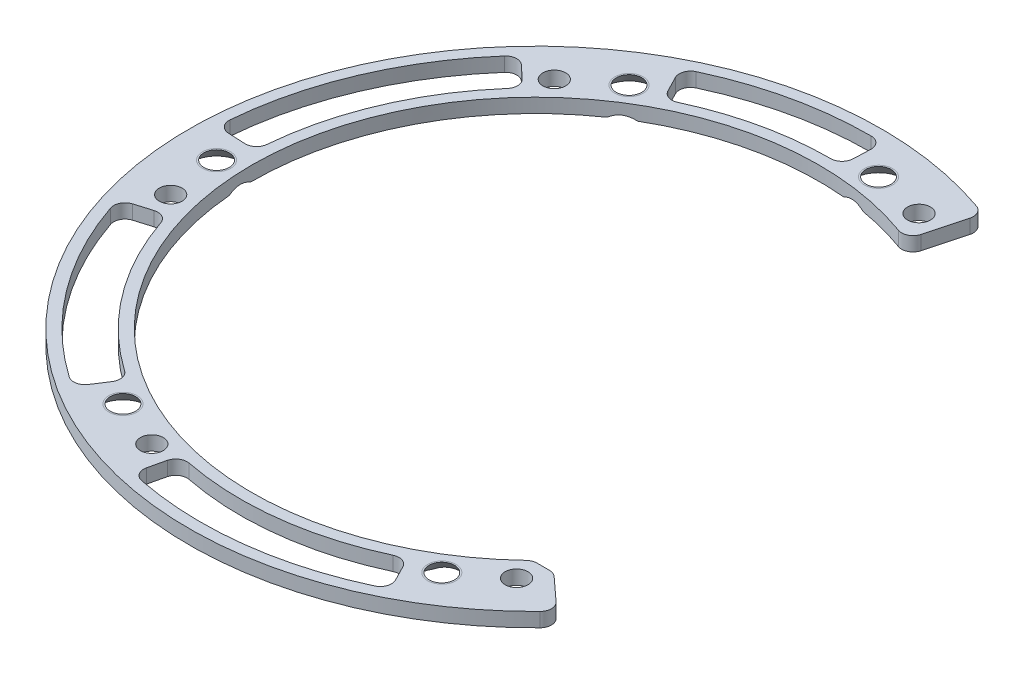
from build123d import *

# Parameters (mm, degrees)
BOSS_EXTRUDE1_DEPTH                          = 3.175
F_10_CLEARANCE_HOLE1_D                       = 5.1054
F_10_CLEARANCE_HOLE1_DEPTH                   = 3.175
CSK_FOR_10_FLAT_HEAD_MACHINE_SCREW1_AT_COUNT = 2
CSK_FOR_10_FLAT_HEAD_MACHINE_SCREW1_AT_PITCH = 46.824609742
CSK_FOR_10_FLAT_HEAD_MACHINE_SCREW1_2_COUNT  = 2
CSK_FOR_10_FLAT_HEAD_MACHINE_SCREW1_2_PITCH  = 104.87608053
CSK_FOR_10_FLAT_HEAD_MACHINE_SCREW1_3_COUNT  = 2
CSK_FOR_10_FLAT_HEAD_MACHINE_SCREW1_3_PITCH  = 134.826090234
CSK_FOR_10_FLAT_HEAD_MACHINE_SCREW1_4_COUNT  = 2
CSK_FOR_10_FLAT_HEAD_MACHINE_SCREW1_4_PITCH  = 128.649557941
FILLET1_R                                    = 2.54
CUT_EXTRUDE1_REACH                           = 5.175


with BuildPart() as part:
    # Sketch6 → Boss-Extrude1 (new body)
    with BuildSketch(Plane(origin=(0, -75.25766, 0), x_dir=(1, 0, 0), z_dir=(0, 1, 0))):
        with BuildLine():
            ThreePointArc((27.776705308, 72.346331375), (-75.433008797, -17.75945396), (57.135602127, -52.355133375))
            Line((57.135602127, -52.355133375), (49.374216067, -45.243133375))
            Line((49.374216067, -45.243133375), (44.556805119, -45.243133375))
            ThreePointArc((44.556805119, -45.243133375), (-62.309050026, -12.240599855), (24.13, 58.736641886))
            Line((24.13, 58.736641886), (27.776705308, 72.346331375))
        make_face()
    extrude(amount=-BOSS_EXTRUDE1_DEPTH)

    # #10 Clearance Hole1
    with Locations(Plane(origin=(0, -75.25766, 0), x_dir=(1, 0, 0), z_dir=(0, 1, 0))):
        with Locations((-46.246176482, 50.468845537), (20.584214093, 65.28478643), (-66.830390575, -14.815940893), (-20.584214093, -65.28478643), (46.246176482, -50.468845537)):
            Hole(F_10_CLEARANCE_HOLE1_D / 2, depth=F_10_CLEARANCE_HOLE1_DEPTH)

    # Sketch10 → CSK for #10 Flat Head Machine Screw1 (revolve, cut)
    with BuildSketch(Plane(origin=(8.934909436, -78.43266, -67.867375096), x_dir=(0, 0, -1), z_dir=(1, 0, 0))):
        Polygon((0, 0), (0, 3.175), (2.5527, 3.175), (2.5527, 3.506322905), (5.6007, 0), align=None)
    csk_for_10_flat_head_machine_screw1 = revolve(axis=Axis((8.934909436, -84.78266, -67.867375096), (0, 1, 0)), mode=Mode.SUBTRACT)

    # CSK for #10 Flat Head Machine Screw1 at: CSK for #10 Flat Head Machine Screw1 ×2
    with Locations(*[Vector(-0.976296007, 0, 0.216439614) * (i * CSK_FOR_10_FLAT_HEAD_MACHINE_SCREW1_AT_PITCH) for i in range(1, CSK_FOR_10_FLAT_HEAD_MACHINE_SCREW1_AT_COUNT)]):
        add(csk_for_10_flat_head_machine_screw1, mode=Mode.SUBTRACT)

    # CSK for _10 Flat Head Machine Screw1 2: CSK for #10 Flat Head Machine Screw1 ×2
    with Locations(*[Vector(-0.737277337, 0, 0.675590208) * (i * CSK_FOR_10_FLAT_HEAD_MACHINE_SCREW1_2_PITCH) for i in range(1, CSK_FOR_10_FLAT_HEAD_MACHINE_SCREW1_2_COUNT)]):
        add(csk_for_10_flat_head_machine_screw1, mode=Mode.SUBTRACT)

    # CSK for _10 Flat Head Machine Screw1 3: CSK for #10 Flat Head Machine Screw1 ×2
    with Locations(*[Vector(-0.3007058, 0, 0.953716951) * (i * CSK_FOR_10_FLAT_HEAD_MACHINE_SCREW1_3_PITCH) for i in range(1, CSK_FOR_10_FLAT_HEAD_MACHINE_SCREW1_3_COUNT)]):
        add(csk_for_10_flat_head_machine_screw1, mode=Mode.SUBTRACT)

    # CSK for _10 Flat Head Machine Screw1 4: CSK for #10 Flat Head Machine Screw1 ×2
    with Locations(*[Vector(0.216439614, 0, 0.976296007) * (i * CSK_FOR_10_FLAT_HEAD_MACHINE_SCREW1_4_PITCH) for i in range(1, CSK_FOR_10_FLAT_HEAD_MACHINE_SCREW1_4_COUNT)]):
        add(csk_for_10_flat_head_machine_screw1, mode=Mode.SUBTRACT)

    # Fillet1
    fillet1_edges = [part.edges().sort_by_distance(p)[0] for p in [
        (24.13, -76.84516, -58.736641886),
        (27.776705308, -76.84516, -72.346331375),
        (57.135602127, -76.84516, 52.355133375),
        (49.374216067, -76.84516, 45.243133375),
        (44.556805119, -76.84516, 45.243133375),
    ]]
    fillet(fillet1_edges, radius=FILLET1_R)

    # Sketch14 → Cut-Extrude1 (cut, up to next)
    with BuildSketch(Plane(origin=(0, -75.25766, 0), x_dir=(1, 0, 0), z_dir=(0, 1, 0)), mode=Mode.PRIVATE) as cut_extrude1_sk1:
        with BuildLine():
            Line((-33.055101826, 64.380888472), (-31.302158707, 60.966709443))
            ThreePointArc((-31.302158707, 60.966709443), (-29.864658567, 59.723557233), (-27.966930931, 59.825850385))
            ThreePointArc((-27.966930931, 59.825850385), (-14.293672104, 64.47458831), (0.063150386, 66.039969806))
            ThreePointArc((0.063150386, 66.039969806), (1.826306674, 66.749275081), (2.603745418, 68.483467419))
            Line((2.603745418, 68.483467419), (2.749557011, 72.318590234))
            ThreePointArc((2.749557011, 72.318590234), (2.043811589, 74.174021303), (0.21880546, 74.955080637))
            ThreePointArc((0.21880546, 74.955080637), (-16.223317839, 73.178657732), (-31.87569098, 67.839902076))
            ThreePointArc((-31.87569098, 67.839902076), (-33.199618308, 66.360741002), (-33.055101826, 64.380888472))
        make_face()
    cut_extrude1_tool1 = extrude(cut_extrude1_sk1.sketch, amount=-CUT_EXTRUDE1_REACH, mode=Mode.PRIVATE) & part.part
    add(cut_extrude1_tool1.solids().sort_by_distance((-15.117133, -75.25766, -68.188982))[0], mode=Mode.SUBTRACT)
    # Sketch14 → Cut-Extrude1 (cut, up to next)
    with BuildSketch(Plane(origin=(0, -75.25766, 0), x_dir=(1, 0, 0), z_dir=(0, 1, 0)), mode=Mode.PRIVATE) as cut_extrude1_sk2:
        with BuildLine():
            Line((-52.717941235, 49.581823576), (-49.92225926, 46.952452868))
            ThreePointArc((-49.92225926, 46.952452868), (-49.125502701, 45.22705058), (-49.749009498, 43.431758587))
            ThreePointArc((-49.749009498, 43.431758587), (-60.775101299, 25.839285248), (-65.794171702, 5.69285254))
            ThreePointArc((-65.794171702, 5.69285254), (-66.654447051, 3.998225622), (-68.449798516, 3.374890088))
            Line((-68.449798516, 3.374890088), (-72.283035848, 3.56388633))
            ThreePointArc((-72.283035848, 3.56388633), (-74.069896676, 4.42865765), (-74.688924078, 6.314792886))
            ThreePointArc((-74.688924078, 6.314792886), (-68.979739974, 29.327588756), (-56.36825574, 49.405786442))
            ThreePointArc((-56.36825574, 49.405786442), (-54.580464724, 50.268633089), (-52.717941235, 49.581823576))
        make_face()
    cut_extrude1_tool2 = extrude(cut_extrude1_sk2.sketch, amount=-CUT_EXTRUDE1_REACH, mode=Mode.PRIVATE) & part.part
    add(cut_extrude1_tool2.solids().sort_by_distance((-63.655179, -75.25766, -27.063786))[0], mode=Mode.SUBTRACT)
    # Sketch14 → Cut-Extrude1 (cut, up to next)
    with BuildSketch(Plane(origin=(0, -75.25766, 0), x_dir=(1, 0, 0), z_dir=(0, 1, 0)), mode=Mode.PRIVATE) as cut_extrude1_sk3:
        with BuildLine():
            Line((-69.2980894, -20.864164557), (-65.623146584, -19.7577183))
            ThreePointArc((-65.623146584, -19.7577183), (-63.730526092, -19.930408023), (-62.487511016, -21.368026745))
            ThreePointArc((-62.487511016, -21.368026745), (-52.76502809, -39.713139018), (-37.827240771, -54.132997845))
            ThreePointArc((-37.827240771, -54.132997845), (-36.789788484, -55.725331611), (-37.147639809, -57.591819355))
            Line((-37.147639809, -57.591819355), (-39.227934022, -60.817002142))
            ThreePointArc((-39.227934022, -60.817002142), (-40.870278368, -61.932083352), (-42.813233098, -61.52510919))
            ThreePointArc((-42.813233098, -61.52510919), (-59.888306882, -45.074412786), (-70.970794023, -24.113448217))
            ThreePointArc((-70.970794023, -24.113448217), (-70.824145631, -22.133752457), (-69.2980894, -20.864164557))
        make_face()
    cut_extrude1_tool3 = extrude(cut_extrude1_sk3.sketch, amount=-CUT_EXTRUDE1_REACH, mode=Mode.PRIVATE) & part.part
    add(cut_extrude1_tool3.solids().sort_by_distance((-55.265515, -75.25766, 41.595109))[0], mode=Mode.SUBTRACT)
    # Sketch14 → Cut-Extrude1 (cut, up to next)
    with BuildSketch(Plane(origin=(0, -75.25766, 0), x_dir=(1, 0, 0), z_dir=(0, 1, 0)), mode=Mode.PRIVATE) as cut_extrude1_sk4:
        with BuildLine():
            Line((-16.580148165, -70.445988133), (-15.700887324, -66.710171168))
            ThreePointArc((-15.700887324, -66.710171168), (-14.60502339, -65.157458603), (-12.738501518, -64.799785332))
            ThreePointArc((-12.738501518, -64.799785332), (8.010073209, -65.552424266), (27.966930931, -59.825850385))
            ThreePointArc((27.966930931, -59.825850385), (29.864658567, -59.723557233), (31.302158707, -60.966709443))
            Line((31.302158707, -60.966709443), (33.055101826, -64.380888472))
            ThreePointArc((33.055101826, -64.380888472), (33.199618308, -66.360741002), (31.87569098, -67.839902076))
            ThreePointArc((31.87569098, -67.839902076), (9.091433092, -74.402001542), (-14.602538283, -73.519234659))
            ThreePointArc((-14.602538283, -73.519234659), (-16.243680907, -72.402385546), (-16.580148165, -70.445988133))
        make_face()
    cut_extrude1_tool4 = extrude(cut_extrude1_sk4.sketch, amount=-CUT_EXTRUDE1_REACH, mode=Mode.PRIVATE) & part.part
    add(cut_extrude1_tool4.solids().sort_by_distance((8.389663, -75.25766, 68.658895))[0], mode=Mode.SUBTRACT)


solid = part.part
